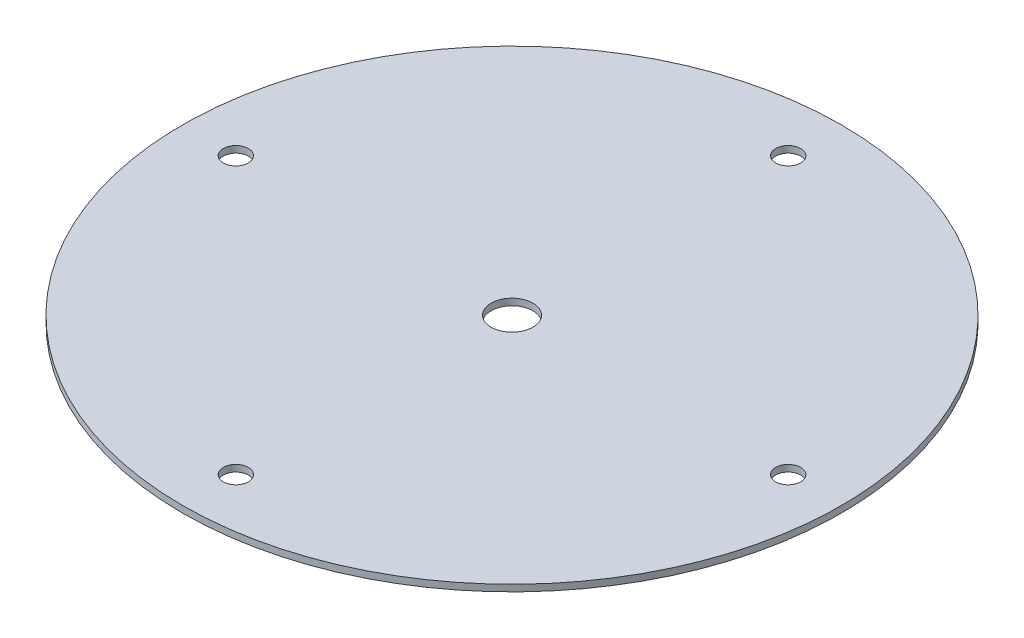
from build123d import *

# Parameters (mm, degrees)
SKETCH1_R           = 79
SKETCH1_R_2         = 3
SKETCH1_R_3         = 5
BOSS_EXTRUDE1_DEPTH = 1.5875


with BuildPart() as part:
    # Sketch1 → Boss-Extrude1 (new body)
    with BuildSketch(Plane(origin=(0, 0, 0), x_dir=(1, 0, 0), z_dir=(0, 1, 0))):
        Circle(SKETCH1_R)
        with Locations((0, 66.2)):
            Circle(SKETCH1_R_2, mode=Mode.SUBTRACT)
        with Locations((66.2, 0)):
            Circle(SKETCH1_R_2, mode=Mode.SUBTRACT)
        with Locations((0, -66.2)):
            Circle(SKETCH1_R_2, mode=Mode.SUBTRACT)
        with Locations((-66.2, 0)):
            Circle(SKETCH1_R_2, mode=Mode.SUBTRACT)
        Circle(SKETCH1_R_3, mode=Mode.SUBTRACT)
    extrude(amount=BOSS_EXTRUDE1_DEPTH)


solid = part.part
